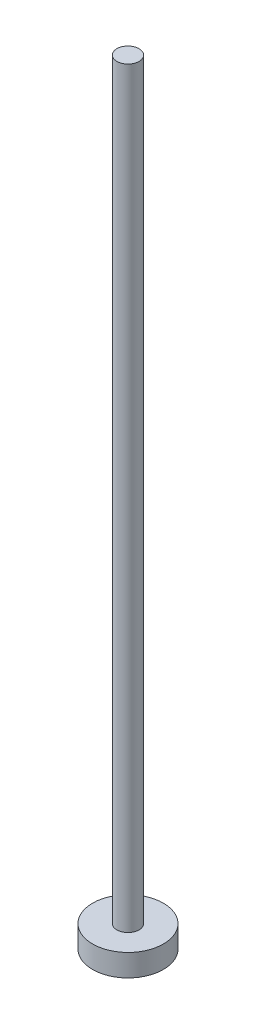
from build123d import *


with BuildPart() as part:
    # Szkic1 → Obrót1 (revolve)
    with BuildSketch(Plane.XY):
        Polygon((0, 175), (0, 0), (8, 0), (8, 5), (2.5, 5), (2.5, 175), align=None)
    revolve(axis=Axis((0, 175, 0), (0, -1, 0)))


solid = part.part
